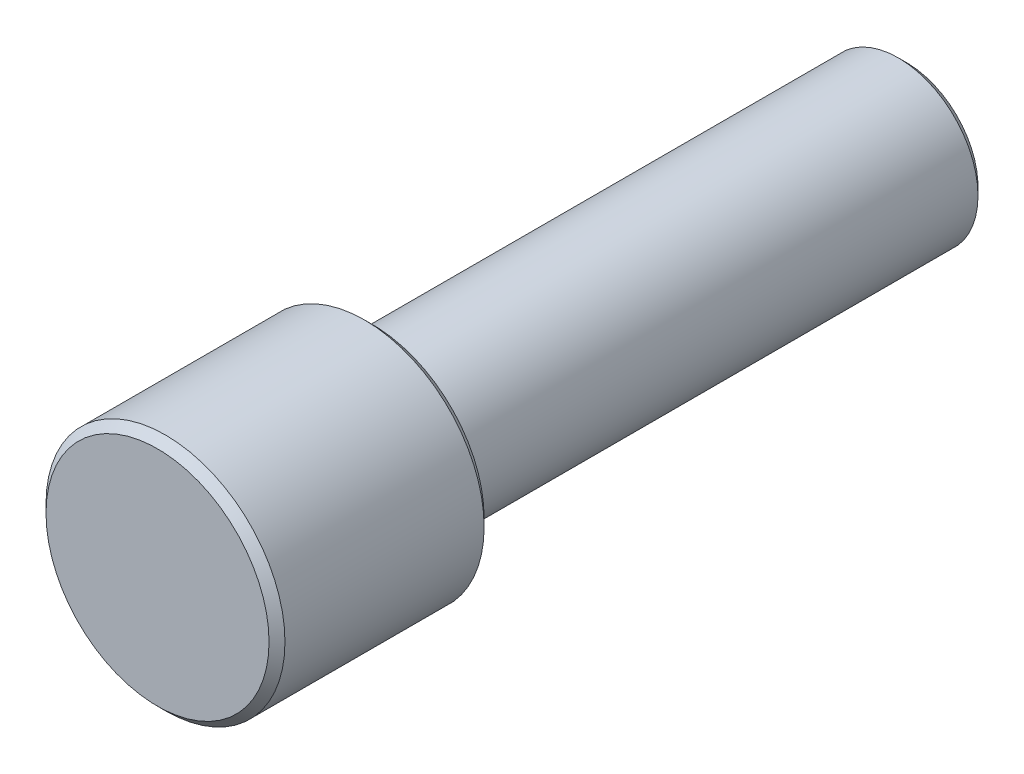
from build123d import *

# Parameters (mm, degrees)
ESQUISSE1_R        = 15
BOSS_EXTRU_1_DEPTH = 27
ESQUISSE2_R        = 10
BOSS_EXTRU_2_DEPTH = 67
CHANFREIN1_SIZE    = 1
CONG_1_R           = 1.5


with BuildPart() as part:
    # Esquisse1 → Boss.-Extru.1 (new body)
    with BuildSketch(Plane.XY):
        Circle(ESQUISSE1_R)
    extrude(amount=BOSS_EXTRU_1_DEPTH)

    # Esquisse2 → Boss.-Extru.2 (add)
    with BuildSketch(Plane(origin=(0, 0, 0), x_dir=(-1, 0, 0), z_dir=(0, 0, -1))):
        with Locations(Location((0, 0, 0), (0, 0, 180))):  # turned: the seam where the file's is
            Circle(ESQUISSE2_R)
    extrude(amount=BOSS_EXTRU_2_DEPTH)

    # Chanfrein1
    chanfrein1_edges = [part.edges().sort_by_distance(p)[0] for p in [
        (-15, 0, 0),
        (-15, 0, 27),
        (-10, 0, -67),
    ]]
    chamfer(chanfrein1_edges, length=CHANFREIN1_SIZE)

    # Congé1
    cong_1_edges = [part.edges().sort_by_distance(p)[0] for p in [
        (-10, 0, 0),
    ]]
    fillet(cong_1_edges, radius=CONG_1_R)


solid = part.part
